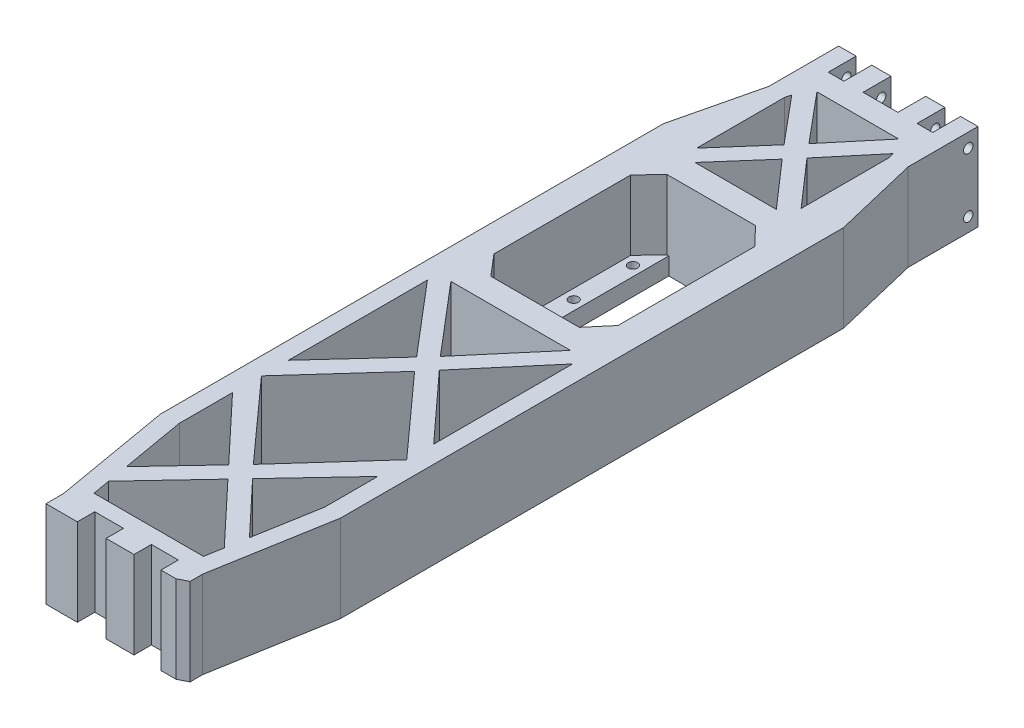
from build123d import *

# Parameters (mm, degrees)
SZKIC1_W                    = 24.4
SZKIC1_H                    = 45
SZKIC1_R                    = 1.35
DODANIE_WYCI_GNI_CIE1_DEPTH = 5
DODANIE_WYCI_GNI_CIE2_DEPTH = 25
WYTNIJ_WYCI_GNI_CIE5_DEPTH  = 178.720894332
SZKIC7_R                    = 1.35
WYTNIJ_WYCI_GNI_CIE6_DEPTH  = 182.638920752
SZKIC8_W                    = 8
SZKIC8_H                    = 5
SZKIC8_W_2                  = 9
DODANIE_WYCI_GNI_CIE3_DEPTH = 25


with BuildPart() as part:
    # Szkic1 → Dodanie-wyci_gni_cie1 (new body)
    with BuildSketch(Plane(origin=(0, 0, 0), x_dir=(1, 0, 0), z_dir=(0, 1, 0))):
        Polygon((14.5, 165.969204133), (10, 165.969204133), (10, 173.969204133), (4.495079248, 173.969204133), (4.495079248, 165.969204133), (-5.495079248, 165.969204133), (-5.495079248, 173.969204133), (-11, 173.969204133), (-11, 165.969204133), (-15.5, 165.969204133), (-15.5, 173.969204133), (-20.5, 173.969204133), (-20.5, 153.940017653), (-26.352083325, 129.486424712), (-26.352083325, -14.915125095), (-20.5, -48.6036745), (19.5, -48.6036745), (25.352083325, -14.915125095), (25.352083325, 129.486424712), (19.5, 153.940017653), (19.5, 173.969204133), (14.5, 173.969204133), align=None)
        with Locations((-0.5, 94.8963255)):
            Rectangle(SZKIC1_W, SZKIC1_H, mode=Mode.SUBTRACT)
        with Locations((14.5, 109.8963255)):
            Circle(SZKIC1_R, mode=Mode.SUBTRACT)
        with Locations((-15.5, 75.8963255)):
            Circle(SZKIC1_R, mode=Mode.SUBTRACT)
        with Locations((-15.5, 92.8963255)):
            Circle(SZKIC1_R, mode=Mode.SUBTRACT)
        with Locations((-15.5, 109.8963255)):
            Circle(SZKIC1_R, mode=Mode.SUBTRACT)
        with Locations((-9, 69.5963255)):
            Circle(SZKIC1_R, mode=Mode.SUBTRACT)
        with Locations((8, 69.5963255)):
            Circle(SZKIC1_R, mode=Mode.SUBTRACT)
        with Locations((14.5, 75.8963255)):
            Circle(SZKIC1_R, mode=Mode.SUBTRACT)
        with Locations((14.5, 92.8963255)):
            Circle(SZKIC1_R, mode=Mode.SUBTRACT)
    extrude(amount=DODANIE_WYCI_GNI_CIE1_DEPTH)

    # Szkic1_3 → Dodanie-wyci_gni_cie2 (add)
    with BuildSketch(Plane(origin=(0, 0, 0), x_dir=(1, 0, 0), z_dir=(0, 1, 0))):
        Polygon((14.5, 165.969204133), (10, 165.969204133), (10, 173.969204133), (4.495079248, 173.969204133), (4.495079248, 165.969204133), (-5.495079248, 165.969204133), (-5.495079248, 173.969204133), (-11, 173.969204133), (-11, 165.969204133), (-15.5, 165.969204133), (-15.5, 173.969204133), (-20.5, 173.969204133), (-20.5, 153.940017653), (-26.352083325, 129.486424712), (-26.352083325, -14.915125095), (-20.5, -48.6036745), (19.5, -48.6036745), (25.352083325, -14.915125095), (25.352083325, 129.486424712), (19.5, 153.940017653), (19.5, 173.969204133), (14.5, 173.969204133), align=None)
        Polygon((-13.2, 117.3963255), (-12.7, 117.3963255), (11.7, 117.3963255), (12.2, 117.3963255), (17.3, 112.070622628), (17.3, 72.7963255), (12.2, 66.7963255), (-13.2, 66.7963255), (-18.3, 72.7963255), (-18.3, 112.070622628), align=None, mode=Mode.SUBTRACT)
    extrude(amount=DODANIE_WYCI_GNI_CIE2_DEPTH)

    # Szkic6 → Wytnij-wyci_gni_cie5 (cut, through all)
    with BuildSketch(Plane(origin=(0, 25, 0), x_dir=(1, 0, 0), z_dir=(0, 1, 0))):
        Polygon((16.653559582, 59.7963255), (-17.653559582, 59.7963255), (-0.5, 39.615667168), align=None)
        Polygon((-21.352083325, 56.74466496), (-21.352083325, 16.848702414), (-3.763614868, 36.052349129), align=None)
        Polygon((2.763614868, 36.052349129), (20.352083325, 16.848702414), (20.352083325, 56.74466496), align=None)
        Polygon((17.161306881, -32.852341508), (20.352083325, -14.484074364), (20.352083325, 0.802588639), (2.931825406, -17.721341562), align=None)
        Polygon((15.206822662, -44.1036745), (16.091150305, -39.01288651), (-0.5, -21.370592599), (-17.091150305, -39.01288651), (-16.206822662, -44.1036745), align=None)
        Polygon((-0.5, -14.072090524), (20.352083325, 9.098992114), (-0.5, 32.212802226), (-21.352083325, 9.098992114), align=None)
        Polygon((-3.931825406, -17.721341562), (-21.352083325, 0.802588639), (-21.352083325, -14.484074364), (-18.161306881, -32.852341508), align=None)
        Polygon((-12.240631704, 159.469204133), (-0.5, 145.434029611), (11.240631704, 159.469204133), align=None)
        Polygon((-15.086387227, 155.078390111), (-15.5, 153.350062298), (-15.5, 128.192615569), (-3.790002176, 141.574284058), align=None)
        Polygon((-12.177951744, 124.3963255), (11.177951744, 124.3963255), (-0.5, 137.741373143), align=None)
        Polygon((14.5, 128.192615569), (14.5, 153.350062298), (14.086387227, 155.078390111), (2.790002176, 141.574284058), align=None)
    extrude(amount=-WYTNIJ_WYCI_GNI_CIE5_DEPTH, mode=Mode.SUBTRACT)

    # Szkic7 → Wytnij-wyci_gni_cie6 (cut, through all)
    with BuildSketch(Plane.ZY.offset(20.5)):
        with Locations((-171.169204133, 21)):
            Circle(SZKIC7_R)
        with Locations((-171.169204133, 4)):
            Circle(SZKIC7_R)
    extrude(amount=-WYTNIJ_WYCI_GNI_CIE6_DEPTH, mode=Mode.SUBTRACT)

    # Szkic8 → Dodanie-wyci_gni_cie3 (add)
    with BuildSketch(Plane(origin=(0, 25, 0), x_dir=(1, 0, 0), z_dir=(0, 1, 0))):
        Polygon((19.5, -52.255545309), (19.5, -48.6036745), (12.5, -48.6036745), (12.5, -53.6036745), (16.83, -53.6036745), align=None)
        with Locations((0.758846465, -51.1036745)):
            Rectangle(SZKIC8_W, SZKIC8_H)
        with Locations((-16, -51.1036745)):
            Rectangle(SZKIC8_W_2, SZKIC8_H)
    extrude(amount=-DODANIE_WYCI_GNI_CIE3_DEPTH)


solid = part.part
